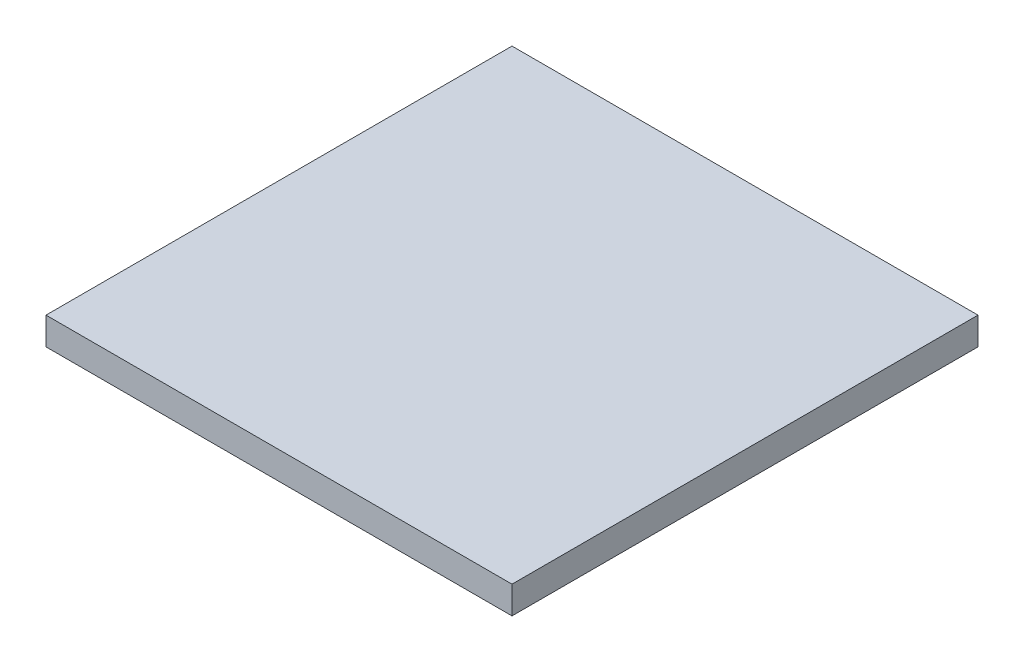
from build123d import *

# Parameters (mm, degrees)
SKETCH_1_W      = 25.4
SKETCH_1_H      = 25.4
EXTRUDE_1_DEPTH = 1.5


with BuildPart() as part:
    # 草图1 → 凸台-拉伸1 (new body)
    with BuildSketch(Plane(origin=(0, 0, 0), x_dir=(1, 0, 0), z_dir=(0, 1, 0))):
        Rectangle(SKETCH_1_W, SKETCH_1_H)
    extrude(amount=EXTRUDE_1_DEPTH)


solid = part.part
